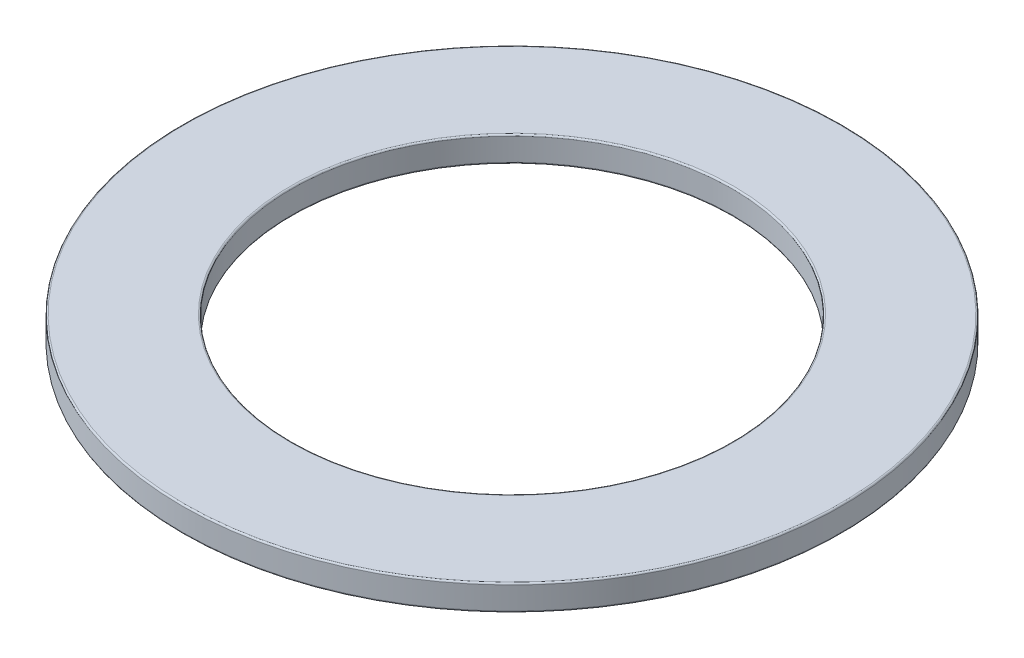
from build123d import *

# Parameters (mm, degrees)
SKETCH4_W = 7.8994
SKETCH4_H = 1.849966709
FILLET3_R = 0.110998


with BuildPart() as part:
    # Sketch4 → Revolve3 (revolve)
    with BuildSketch(Plane(origin=(0, 0, 0), x_dir=(0, 0, -1), z_dir=(1, 0, 0))):
        with Locations((-19.8628, -4.624916645)):
            Rectangle(SKETCH4_W, SKETCH4_H)
    revolve(axis=Axis((0, -5.5499, 0), (0, 1, 0)))

    # Fillet3
    fillet3_edges = [part.edges().sort_by_distance(p)[0] for p in [
        (0, -5.5499, -15.9131),
        (0, -3.699933291, -15.9131),
        (0, -5.5499, -23.8125),
        (0, -3.699933291, -23.8125),
    ]]
    fillet(fillet3_edges, radius=FILLET3_R)


solid = part.part
